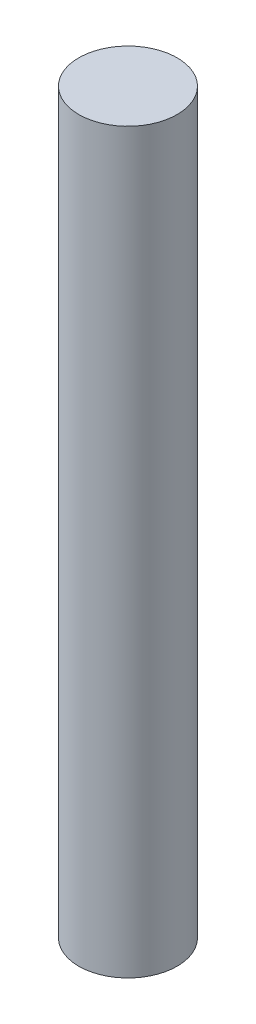
from build123d import *

# Parameters (mm, degrees)
SKETCH1_R           = 20
BOSS_EXTRUDE1_DEPTH = 300


with BuildPart() as part:
    # Sketch1 → Boss-Extrude1 (new body)
    with BuildSketch(Plane(origin=(0, 0, 0), x_dir=(1, 0, 0), z_dir=(0, 1, 0))):
        Circle(SKETCH1_R)
    extrude(amount=BOSS_EXTRUDE1_DEPTH)


solid = part.part
